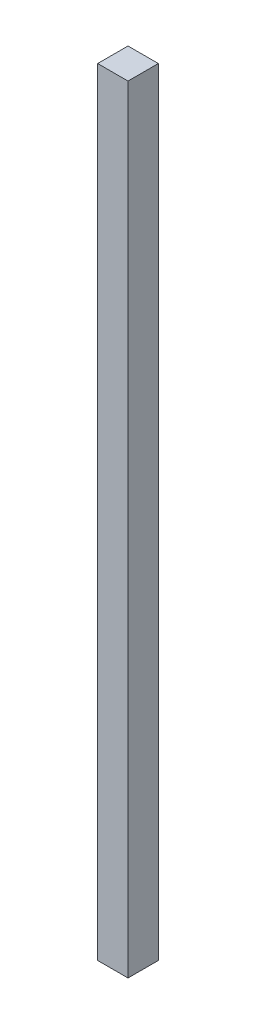
from build123d import *

# Parameters (mm, degrees)
SKETCH_1_W      = 10
SKETCH_1_H      = 10
EXTRUDE_1_DEPTH = 256


with BuildPart() as part:
    # Эскиз1 → Бобышка-Вытянуть1 (new body)
    with BuildSketch(Plane(origin=(0, 0, 0), x_dir=(1, 0, 0), z_dir=(0, 1, 0))):
        Rectangle(SKETCH_1_W, SKETCH_1_H)
    extrude(amount=EXTRUDE_1_DEPTH)


solid = part.part
